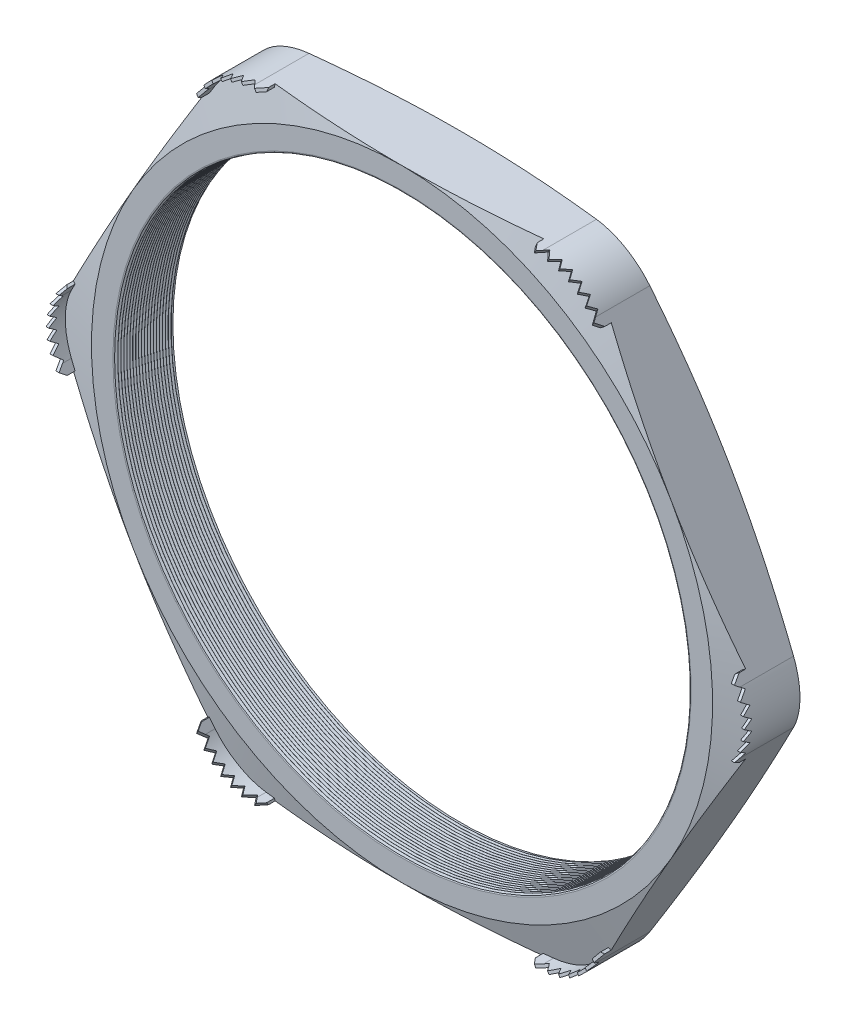
from build123d import *

# Parameters (mm, degrees)
SKETCH1_R          = 29.591
EXTRUDE1_DEPTH     = 6.096
FILLET1_R          = 6.35
FILLET3_R          = 0.2032
LPATTERN1_COUNT    = 20
LPATTERN1_PITCH    = 0.3048
SKETCH4_OUTSIDE_W  = 146.21
SKETCH4_OUTSIDE_H  = 138.272
SKETCH4_OUTSIDE_R  = 32.004
CUT_EXTRUDE1_DEPTH = 7.0960001
CUT_EXTRUDE1_DRAFT = -75
SKETCH5_OUTSIDE_W  = 146.21
SKETCH5_OUTSIDE_H  = 138.272
SKETCH5_OUTSIDE_R  = 32.004
CUT_EXTRUDE2_DEPTH = 7.0960001
CUT_EXTRUDE2_DRAFT = -75
EXTRUDE2_START     = -1.063407
EXTRUDE2_DEPTH     = 2.968407
CUT_EXTRUDE4_DEPTH = 12.305239537
CIRPATTERN1_COUNT  = 6
CIRPATTERN2_COUNT  = 6


with BuildPart() as part:
    # Sketch1 → Extrude1 (new body)
    with BuildSketch(Plane.XY):
        Polygon((-36.95503603, 0), (-18.477518015, -32.004), (18.477518015, -32.004), (36.95503603, 0), (18.477518015, 32.004), (-18.477518015, 32.004), align=None)
        Circle(SKETCH1_R, mode=Mode.SUBTRACT)
    extrude(amount=EXTRUDE1_DEPTH)

    # Fillet1
    fillet1_edges = [part.edges().sort_by_distance(p)[0] for p in [
        (36.95503603, 0, 3.048),
        (18.477518015, -32.004, 3.048),
        (-18.477518015, -32.004, 3.048),
        (-36.95503603, 0, 3.048),
        (-18.477518015, 32.004, 3.048),
        (18.477518015, 32.004, 3.048),
    ]]
    fillet(fillet1_edges, radius=FILLET1_R)

    # Fillet3
    fillet3_edges = [part.edges().sort_by_distance(p)[0] for p in [
        (-29.591, 0, 0),
        (-29.591, 0, 6.096),
    ]]
    fillet(fillet3_edges, radius=FILLET3_R)

    # Sketch3 → Cut-Revolve1 (revolve, cut)
    with BuildSketch(Plane(origin=(0, 0, 0), x_dir=(1, 0, 0), z_dir=(0, 1, 0))):
        Polygon((-29.591, -6.096), (-29.591, -5.802706063), (-29.845, -5.949353032), align=None)
    cut_revolve1 = revolve(axis=Axis((0, 0, 6.096), (0, 0, -1)), mode=Mode.SUBTRACT)

    # LPattern1: Cut-Revolve1 ×20
    with Locations(*[(0, 0, -i * LPATTERN1_PITCH) for i in range(1, LPATTERN1_COUNT)]):
        add(cut_revolve1, mode=Mode.SUBTRACT)


with BuildPart() as cut_extrude1_tool:
    # Sketch4 outside → Cut-Extrude1 (with draft: the straight prism first)
    with BuildSketch(Plane(origin=(0, 0, 0), x_dir=(-1, 0, 0), z_dir=(0, 0, -1))):
        Rectangle(SKETCH4_OUTSIDE_W, SKETCH4_OUTSIDE_H)
        Circle(SKETCH4_OUTSIDE_R, mode=Mode.SUBTRACT)
    extrude(amount=-CUT_EXTRUDE1_DEPTH)
    # Cut-Extrude1: the draft: its side faces are tilted about the plane it starts from
    cut_extrude1_sides = [cut_extrude1_tool.faces().sort_by_distance(p)[0] for p in [
        (0, -69.136, 3.54800005),
        (-73.105, 0, 3.54800005),
        (0, 69.136, 3.54800005),
        (73.105, 0, 3.54800005),
        (32.004, 0, 3.54800005),
    ]]
    draft(cut_extrude1_sides, Plane(origin=(0, 0, 0), x_dir=(-1, 0, 0), z_dir=(0, 0, -1)), CUT_EXTRUDE1_DRAFT)


with BuildPart() as part_1:
    add(part.part)

    # Cut-Extrude1: cut by cut_extrude1_tool
    add(cut_extrude1_tool.part, mode=Mode.SUBTRACT)


with BuildPart() as cut_extrude2_tool:
    # Sketch5 outside → Cut-Extrude2 (with draft: the straight prism first)
    with BuildSketch(Plane.XY.offset(6.096)):
        Rectangle(SKETCH5_OUTSIDE_W, SKETCH5_OUTSIDE_H)
        Circle(SKETCH5_OUTSIDE_R, mode=Mode.SUBTRACT)
    extrude(amount=-CUT_EXTRUDE2_DEPTH)
    # Cut-Extrude2: the draft: its side faces are tilted about the plane it starts from
    cut_extrude2_sides = [cut_extrude2_tool.faces().sort_by_distance(p)[0] for p in [
        (0, -69.136, 2.54799995),
        (73.105, 0, 2.54799995),
        (0, 69.136, 2.54799995),
        (-73.105, 0, 2.54799995),
        (-32.004, 0, 2.54799995),
    ]]
    draft(cut_extrude2_sides, Plane.XY.offset(6.096), CUT_EXTRUDE2_DRAFT)


with BuildPart() as part_2:
    add(part_1.part)

    # Cut-Extrude2: cut by cut_extrude2_tool
    add(cut_extrude2_tool.part, mode=Mode.SUBTRACT)

    # Sketch2 → Extrude2 (add)
    with BuildSketch(Plane.XY.offset(6.096).offset(EXTRUDE2_START)):
        with BuildLine():
            Line((-14.811343806, 32.004), (-13.846143806, 32.004))
            Line((-13.846143806, 32.004), (-13.846143806, 31.7246))
            Line((-13.846143806, 31.7246), (-14.811343806, 31.7246))
            ThreePointArc((-14.811343806, 31.7246), (-17.846643806, 30.911293816), (-20.068637622, 28.6893))
            Line((-20.068637622, 28.6893), (-20.551237622, 27.85341228))
            Line((-20.551237622, 27.85341228), (-20.79320512, 27.99311228))
            Line((-20.79320512, 27.99311228), (-20.31060512, 28.829))
            ThreePointArc((-20.31060512, 28.829), (-17.986343806, 31.153261314), (-14.811343806, 32.004))
        make_face()
    extrude2 = extrude(amount=EXTRUDE2_DEPTH)

    # Sketch7 → Cut-Extrude4 (cut, through all)
    with BuildSketch(Plane(origin=(-17.198690714, 29.78900614, 0), x_dir=(0.866025404, 0.5, 0), z_dir=(0.5, -0.866025404, 0))):
        Polygon((-4.01088772, 6.00075), (-3.45208772, 6.80085), (-2.89328772, 6.00075), (-2.2352, 6.80085), (-1.6764, 6.00075), (-1.1176, 6.80085), (-0.5588, 6.00075), (0, 6.80085), (0.5588, 6.00075), (1.1176, 6.80085), (1.6764, 6.00075), (2.2352, 6.80085), (2.794, 6.00075), (3.45208772, 6.80085), (4.01088772, 6.00075), (4.01088772, 8.001), (-4.01088772, 8.001), align=None)
    cut_extrude4 = extrude(amount=-CUT_EXTRUDE4_DEPTH, mode=Mode.SUBTRACT)

    # CirPattern1: Extrude2 ×6 about axis
    cirpattern1_axis = Axis((0, 0, 0), (0, 0, 1))
    for i in range(1, CIRPATTERN1_COUNT):
        add(extrude2.rotate(cirpattern1_axis, i * 360 / CIRPATTERN1_COUNT))

    # CirPattern2: Cut-Extrude4 ×6 about axis
    cirpattern2_axis = Axis((0, 0, 0), (0, 0, 1))
    for i in range(1, CIRPATTERN2_COUNT):
        add(cut_extrude4.rotate(cirpattern2_axis, i * 360 / CIRPATTERN2_COUNT), mode=Mode.SUBTRACT)


solid = part_2.part
